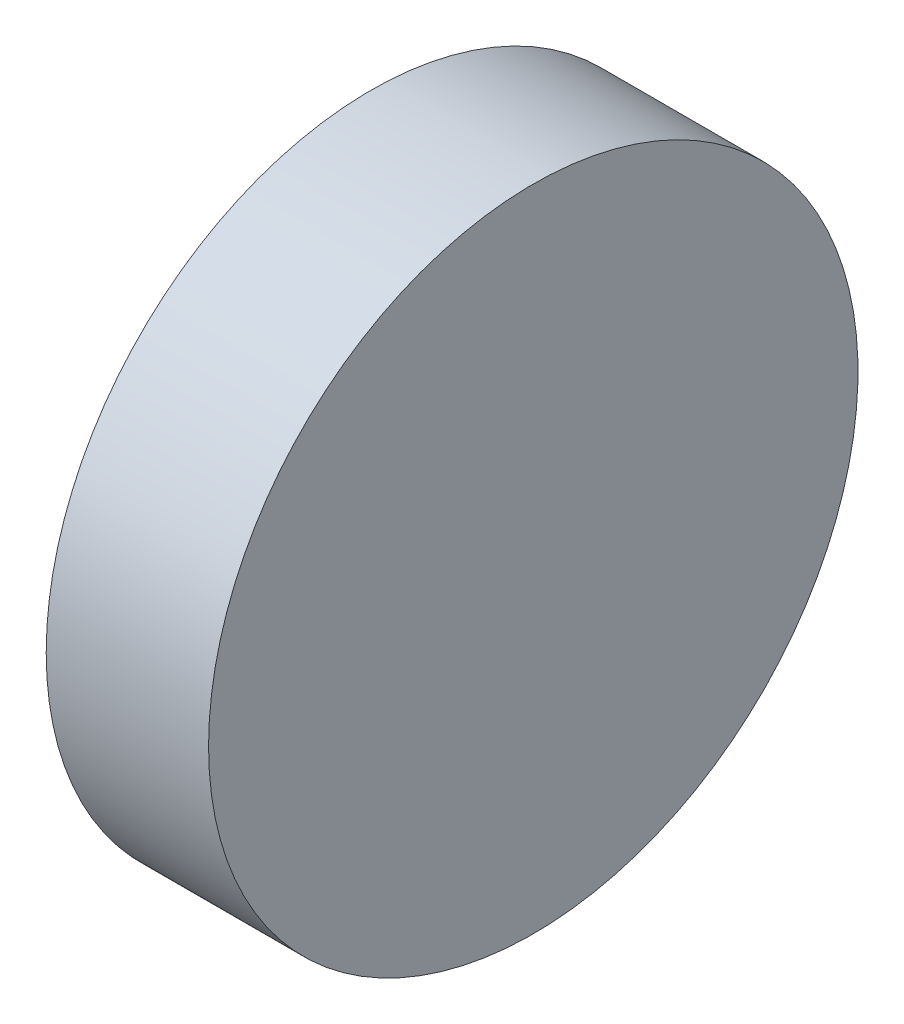
from build123d import *

# Parameters (mm, degrees)
SKETCH_1_W = 6.35
SKETCH_1_H = 12.7


with BuildPart() as part:
    # 草图1 → 旋转1 (revolve)
    with BuildSketch(Plane(origin=(0, 0, 0), x_dir=(1, 0, 0), z_dir=(0, 1, 0))):
        with Locations((3.175, -6.35)):
            Rectangle(SKETCH_1_W, SKETCH_1_H)
    revolve(axis=Axis((-5.443049946, 0, 0), (1, 0, 0)))


solid = part.part
